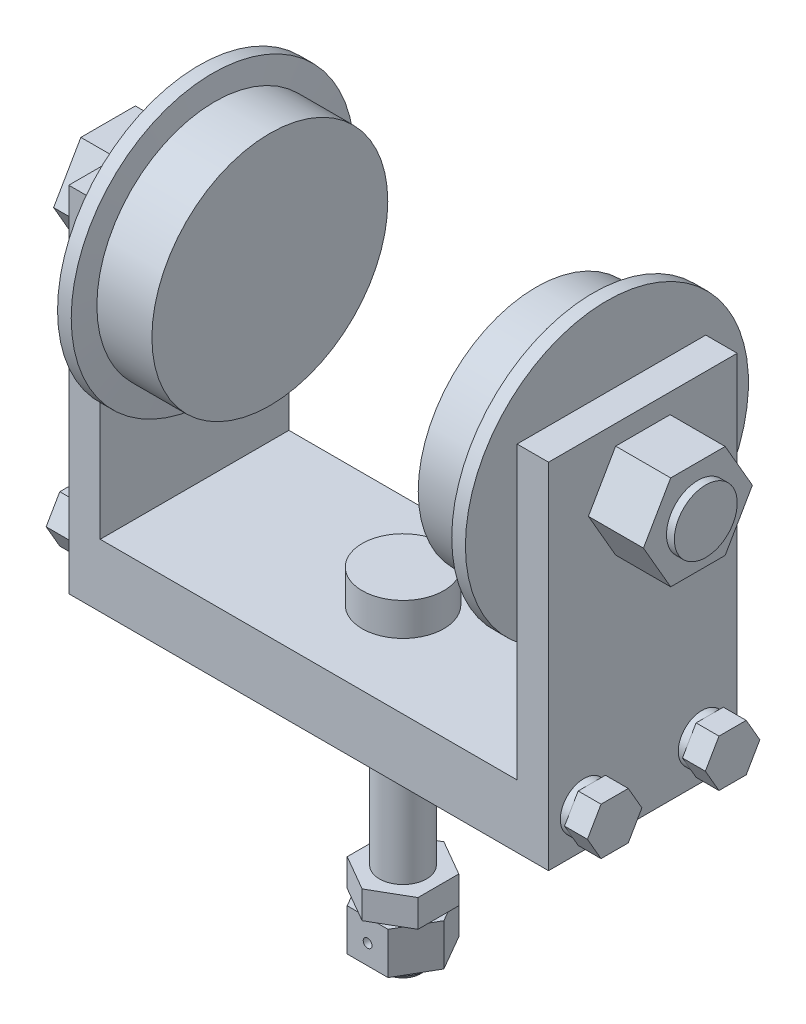
from build123d import *

# Parameters (mm, degrees)
YOKE_CROSS_SECTION_W           = 76.2
YOKE_CROSS_SECTION_H           = 25.4
YOKE_DEPTH                     = 84.163983
SIDEPLATE_PROFILE_W            = 76.2
SIDEPLATE_PROFILE_H            = 142.875
SIDEPLATE_DEPTH                = 12.7
WHEEL_PIN_NUT_DEPTH            = 22.225
WHEEL_PIN_PROJECTION_PROFILE_R = 12.7
WHEEL_PIN_PROJECTION_DEPTH     = 3.175
LOCKNUTS_PROFILE_R             = 9.525
LOCKNUTS_DEPTH                 = 3.175
SCREWS_DEPTH                   = 9.2456
PROFILE_R                      = 16.4973
KING_BOLT_HEAD_DEPTH           = 13.3096
DIA_R                          = 9.525
KING_BOLT_DEPTH                = 65.589601
KING_BOLT_JAM_NUT_DEPTH        = 11.1125
KING_BOLT_NUT_DEPTH            = 16.891
SKETCH5_R                      = 9.525
EXTENDED_KING_BOLT_DEPTH       = 6.35
CHAMFER1_SIZE                  = 2.38125
COTTER_PIN_HOLE_REACH          = 73.437
SKETCH8_R                      = 1.778


with BuildPart() as part:
    # YOKE CROSS SECTION → YOKE (new body)
    with BuildSketch(Plane(origin=(0, 0, 0), x_dir=(0, 0, -1), z_dir=(1, 0, 0))):
        with Locations((0, 12.7)):
            Rectangle(YOKE_CROSS_SECTION_W, YOKE_CROSS_SECTION_H)
    extrude(amount=YOKE_DEPTH)

    # SIDEPLATE PROFILE → SIDEPLATE (add)
    with BuildSketch(Plane(origin=(84.163982525, 0, 0), x_dir=(0, 0, -1), z_dir=(1, 0, 0))):
        with Locations((0, 71.4375)):
            Rectangle(SIDEPLATE_PROFILE_W, SIDEPLATE_PROFILE_H)
    extrude(amount=SIDEPLATE_DEPTH)

    # WHEEL PIN NUT PROFILE → WHEEL PIN NUT (add)
    with BuildSketch(Plane(origin=(96.863982525, 0, 0), x_dir=(0, 0, -1), z_dir=(1, 0, 0))):
        Polygon((21.997045256, 115.8875), (10.998522628, 134.9375), (-10.998522628, 134.9375), (-21.997045256, 115.8875), (-10.998522628, 96.8375), (10.998522628, 96.8375), align=None)
    extrude(amount=WHEEL_PIN_NUT_DEPTH)

    # WHEEL PIN PROJECTION PROFILE → WHEEL PIN PROJECTION (add)
    with BuildSketch(Plane(origin=(119.088982525, 0, 0), x_dir=(0, 0, -1), z_dir=(1, 0, 0))):
        with Locations((0, 115.8875)):
            Circle(WHEEL_PIN_PROJECTION_PROFILE_R)
    extrude(amount=WHEEL_PIN_PROJECTION_DEPTH)

    # LOCKNUTS PROFILE → LOCKNUTS (add)
    with BuildSketch(Plane(origin=(96.863982525, 0, 0), x_dir=(0, 0, -1), z_dir=(1, 0, 0))):
        with Locations((-23.8125, 15.563196315)):
            Circle(LOCKNUTS_PROFILE_R)
    locknuts = extrude(amount=LOCKNUTS_DEPTH)

    # SCREWS PROFILE → SCREWS (add)
    with BuildSketch(Plane(origin=(100.038982525, 0, 0), x_dir=(0, 0, -1), z_dir=(1, 0, 0))):
        Polygon((-12.813977372, 15.563196315), (-18.313238686, 25.088196315), (-29.311761314, 25.088196315), (-34.811022628, 15.563196315), (-29.311761314, 6.038196315), (-18.313238686, 6.038196315), align=None)
    screws = extrude(amount=SCREWS_DEPTH)

    # PROFILE → KING BOLT HEAD (add)
    with BuildSketch(Plane(origin=(0, 25.4, 0), x_dir=(-1, 0, 0), z_dir=(0, 1, 0))):
        with Locations(Location((0, 0, 0), (0, 0, 90))):  # turned: the seam where the file's is
            Circle(PROFILE_R)
    extrude(amount=KING_BOLT_HEAD_DEPTH)

    # Mirror1: LOCKNUTS, SCREWS across plane
    add(locknuts.mirror(Plane.XY))
    add(screws.mirror(Plane.XY))

    # Mirror5: part across plane


with BuildPart() as part_1:
    add(part.part)
    add(part.part.mirror(Plane(origin=(0, 0, 0), x_dir=(0, 0, 1), z_dir=(1, 0, 0))))

    # DIA. → KING BOLT (add)
    with BuildSketch(Plane.XZ):
        with Locations(Location((0, 0, 0), (0, 0, 90))):  # turned: the seam where the file's is
            Circle(DIA_R)
    extrude(amount=KING_BOLT_DEPTH)

    # KING BOLT JAN NUT PROFILE → KING BOLT JAM NUT (add)
    with BuildSketch(Plane.XZ.offset(65.589600888)):
        Polygon((0, -16.497783942), (14.2875, -8.248891971), (14.2875, 8.248891971), (0, 16.497783942), (-14.2875, 8.248891971), (-14.2875, -8.248891971), align=None)
    extrude(amount=KING_BOLT_JAM_NUT_DEPTH)

    # KING BOLT NUT PROFILE → KING BOLT NUT (add)
    with BuildSketch(Plane.XZ.offset(76.702100888)):
        Polygon((16.497783942, 0), (8.248891971, 14.2875), (-8.248891971, 14.2875), (-16.497783942, 0), (-8.248891971, -14.2875), (8.248891971, -14.2875), align=None)
    extrude(amount=KING_BOLT_NUT_DEPTH)

    # Sketch5 → EXTENDED KING BOLT (add)
    with BuildSketch(Plane.XZ.offset(93.593100888)):
        with Locations(Location((0, 0, 0), (0, 0, 90))):  # turned: the seam where the file's is
            Circle(SKETCH5_R)
    extrude(amount=EXTENDED_KING_BOLT_DEPTH)

    # Chamfer1
    chamfer1_edges = [part_1.edges().sort_by_distance(p)[0] for p in [
        (0, -99.943100888, -9.525),
    ]]
    chamfer(chamfer1_edges, length=CHAMFER1_SIZE)

    # Sketch7 → WHEEL (revolve)
    with BuildSketch(Plane.XY, mode=Mode.PRIVATE) as wheel_sk:
        Polygon((53.772235755, 163.5125), (53.772235755, 115.8875), (84.163982525, 115.8875), (84.163982525, 131.7625), (82.347235755, 131.7625), (82.347235755, 173.0375), (76.830565275, 173.0375), (75.997235755, 163.5125), align=None)
    wheel = revolve(wheel_sk.sketch.rotate(Axis((53.772235755, 115.8875, 0), (1, 0, 0)), 90), axis=Axis((53.772235755, 115.8875, 0), (1, 0, 0)))  # turned: the seam where the file's is

    # Mirror6: WHEEL across plane
    add(wheel.mirror(Plane(origin=(0, 0, 0), x_dir=(0, 0, 1), z_dir=(1, 0, 0))))

    # Sketch8 → COTTER PIN HOLE (cut, up to next)
    with BuildSketch(Plane.XY.offset(14.2875), mode=Mode.PRIVATE) as cotter_pin_hole_sk1:
        with Locations((0, -85.655600888)):
            Circle(SKETCH8_R)
    cotter_pin_hole_tool1 = extrude(cotter_pin_hole_sk1.sketch, amount=-COTTER_PIN_HOLE_REACH, mode=Mode.PRIVATE) & part_1.part
    add(cotter_pin_hole_tool1.solids().sort_by_distance((0, -85.655601, 14.2875))[0], mode=Mode.SUBTRACT)


solid = part_1.part
